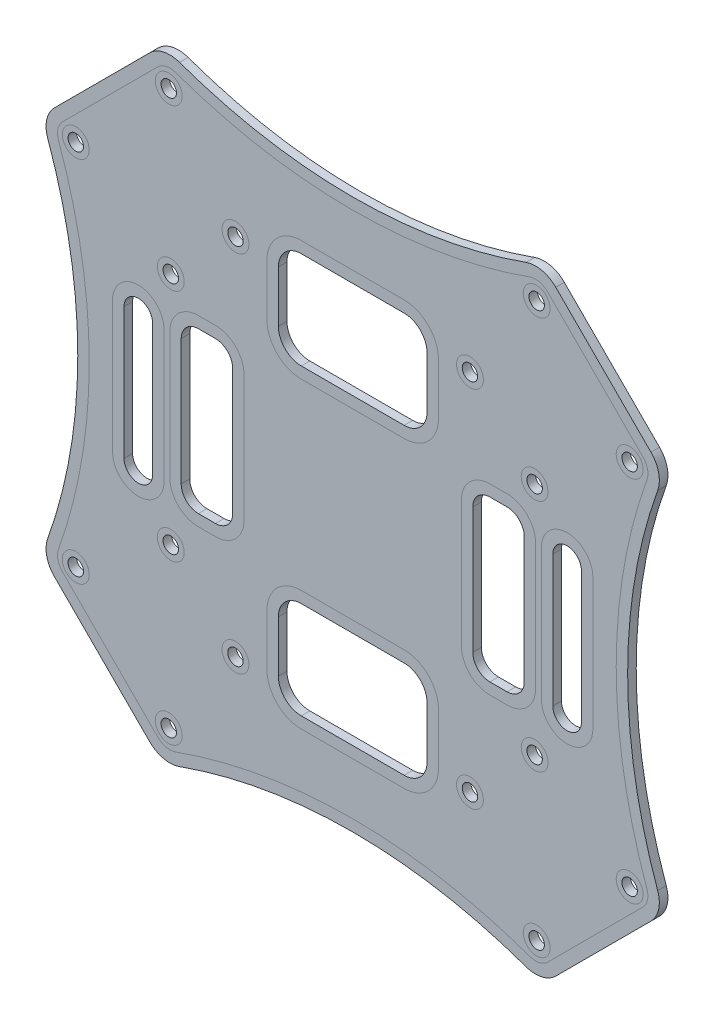
from build123d import *

# Parameters (mm, degrees)
IZIM1_R                     = 1.35
Y_KSEKLIK_EKSTR_ZYON1_DEPTH = 1.5
RADYUS1_R                   = 5


with BuildPart() as part:
    # Çizim1 → Yükseklik-Ekstrüzyon1 (new body)
    with BuildSketch(Plane.XY):
        with BuildLine():
            Line((43.840620434, -43.840620434), (54.447222151, -33.234018716))
            ThreePointArc((54.447222151, -33.234018716), (48.086327838, 0), (54.447222151, 33.234018716))
            Line((54.447222151, 33.234018716), (43.840620434, 43.840620434))
            Line((43.840620434, 43.840620434), (33.234018716, 54.447222151))
            ThreePointArc((33.234018716, 54.447222151), (0, 48.086327838), (-33.234018716, 54.447222151))
            Line((-33.234018716, 54.447222151), (-43.840620434, 43.840620434))
            Line((-43.840620434, 43.840620434), (-54.447222151, 33.234018716))
            ThreePointArc((-54.447222151, 33.234018716), (-48.086327838, 0), (-54.447222151, -33.234018716))
            Line((-54.447222151, -33.234018716), (-43.840620434, -43.840620434))
            Line((-43.840620434, -43.840620434), (-33.234018716, -54.447222151))
            ThreePointArc((-33.234018716, -54.447222151), (0, -48.086327838), (33.234018716, -54.447222151))
            Line((33.234018716, -54.447222151), (43.840620434, -43.840620434))
        make_face()
        with Locations((-32.173358544, 48.436814511)):
            Circle(IZIM1_R, mode=Mode.SUBTRACT)
        with Locations((-48.436814511, 32.173358544)):
            Circle(IZIM1_R, mode=Mode.SUBTRACT)
        with Locations((-31.819805153, 20.506096654)):
            Circle(IZIM1_R, mode=Mode.SUBTRACT)
        with Locations((-20.506096654, 31.819805153)):
            Circle(IZIM1_R, mode=Mode.SUBTRACT)
        with Locations((48.436814511, 32.173358544)):
            Circle(IZIM1_R, mode=Mode.SUBTRACT)
        with Locations((32.173358544, 48.436814511)):
            Circle(IZIM1_R, mode=Mode.SUBTRACT)
        with Locations((31.819805153, 20.506096654)):
            Circle(IZIM1_R, mode=Mode.SUBTRACT)
        with Locations((20.506096654, 31.819805153)):
            Circle(IZIM1_R, mode=Mode.SUBTRACT)
        with Locations((32.173358544, -48.436814511)):
            Circle(IZIM1_R, mode=Mode.SUBTRACT)
        with Locations((48.436814511, -32.173358544)):
            Circle(IZIM1_R, mode=Mode.SUBTRACT)
        with Locations((31.819805153, -20.506096654)):
            Circle(IZIM1_R, mode=Mode.SUBTRACT)
        with Locations((20.506096654, -31.819805153)):
            Circle(IZIM1_R, mode=Mode.SUBTRACT)
        with Locations((-32.173358544, -48.436814511)):
            Circle(IZIM1_R, mode=Mode.SUBTRACT)
        with Locations((-48.436814511, -32.173358544)):
            Circle(IZIM1_R, mode=Mode.SUBTRACT)
        with Locations((-31.819805153, -20.506096654)):
            Circle(IZIM1_R, mode=Mode.SUBTRACT)
        with Locations((-20.506096654, -31.819805153)):
            Circle(IZIM1_R, mode=Mode.SUBTRACT)
        with BuildLine():
            Line((-9, 18), (9, 18))
            ThreePointArc((9, 18), (11.828427125, 19.171572875), (13, 22))
            Line((13, 22), (13, 31))
            ThreePointArc((13, 31), (11.828427125, 33.828427125), (9, 35))
            Line((9, 35), (-9, 35))
            ThreePointArc((-9, 35), (-11.828427125, 33.828427125), (-13, 31))
            Line((-13, 31), (-13, 22))
            ThreePointArc((-13, 22), (-11.828427125, 19.171572875), (-9, 18))
        make_face(mode=Mode.SUBTRACT)
        with BuildLine():
            Line((13, -22), (13, -31))
            ThreePointArc((13, -31), (11.828427125, -33.828427125), (9, -35))
            Line((9, -35), (-9, -35))
            ThreePointArc((-9, -35), (-11.828427125, -33.828427125), (-13, -31))
            Line((-13, -31), (-13, -22))
            ThreePointArc((-13, -22), (-11.828427125, -19.171572875), (-9, -18))
            Line((-9, -18), (9, -18))
            ThreePointArc((9, -18), (11.828427125, -19.171572875), (13, -22))
        make_face(mode=Mode.SUBTRACT)
        with BuildLine():
            Line((35, -11.5), (35, 11.5))
            ThreePointArc((35, 11.5), (37.5, 14), (40, 11.5))
            Line((40, 11.5), (40, -11.5))
            ThreePointArc((40, -11.5), (37.5, -14), (35, -11.5))
        make_face(mode=Mode.SUBTRACT)
        with BuildLine():
            Line((24, -13.362927962), (27, -13.362927962))
            ThreePointArc((27, -13.362927962), (29.121320344, -12.484248306), (30, -10.362927962))
            Line((30, -10.362927962), (30, 11.637072038))
            ThreePointArc((30, 11.637072038), (29.121320344, 13.758392381), (27, 14.637072038))
            Line((27, 14.637072038), (24, 14.637072038))
            ThreePointArc((24, 14.637072038), (21.878679656, 13.758392381), (21, 11.637072038))
            Line((21, 11.637072038), (21, -10.362927962))
            ThreePointArc((21, -10.362927962), (21.878679656, -12.484248306), (24, -13.362927962))
        make_face(mode=Mode.SUBTRACT)
        with BuildLine():
            Line((-35, -11.5), (-35, 11.5))
            ThreePointArc((-35, 11.5), (-37.5, 14), (-40, 11.5))
            Line((-40, 11.5), (-40, -11.5))
            ThreePointArc((-40, -11.5), (-37.5, -14), (-35, -11.5))
        make_face(mode=Mode.SUBTRACT)
        with BuildLine():
            Line((-30, -10.362927962), (-30, 11.637072038))
            ThreePointArc((-30, 11.637072038), (-29.121320344, 13.758392381), (-27, 14.637072038))
            Line((-27, 14.637072038), (-24, 14.637072038))
            ThreePointArc((-24, 14.637072038), (-21.878679656, 13.758392381), (-21, 11.637072038))
            Line((-21, 11.637072038), (-21, -10.362927962))
            ThreePointArc((-21, -10.362927962), (-21.878679656, -12.484248306), (-24, -13.362927962))
            Line((-24, -13.362927962), (-27, -13.362927962))
            ThreePointArc((-27, -13.362927962), (-29.121320344, -12.484248306), (-30, -10.362927962))
        make_face(mode=Mode.SUBTRACT)
    extrude(amount=Y_KSEKLIK_EKSTR_ZYON1_DEPTH)

    # Radyus1
    radyus1_edges = [part.edges().sort_by_distance(p)[0] for p in [
        (33.234018716, -54.447222151, 0.75),
        (-33.234018716, -54.447222151, 0.75),
        (-54.447222151, -33.234018716, 0.75),
        (-54.447222151, 33.234018716, 0.75),
        (-33.234018716, 54.447222151, 0.75),
        (33.234018716, 54.447222151, 0.75),
        (54.447222151, 33.234018716, 0.75),
        (54.447222151, -33.234018716, 0.75),
    ]]
    fillet(radyus1_edges, radius=RADYUS1_R)


solid = part.part
